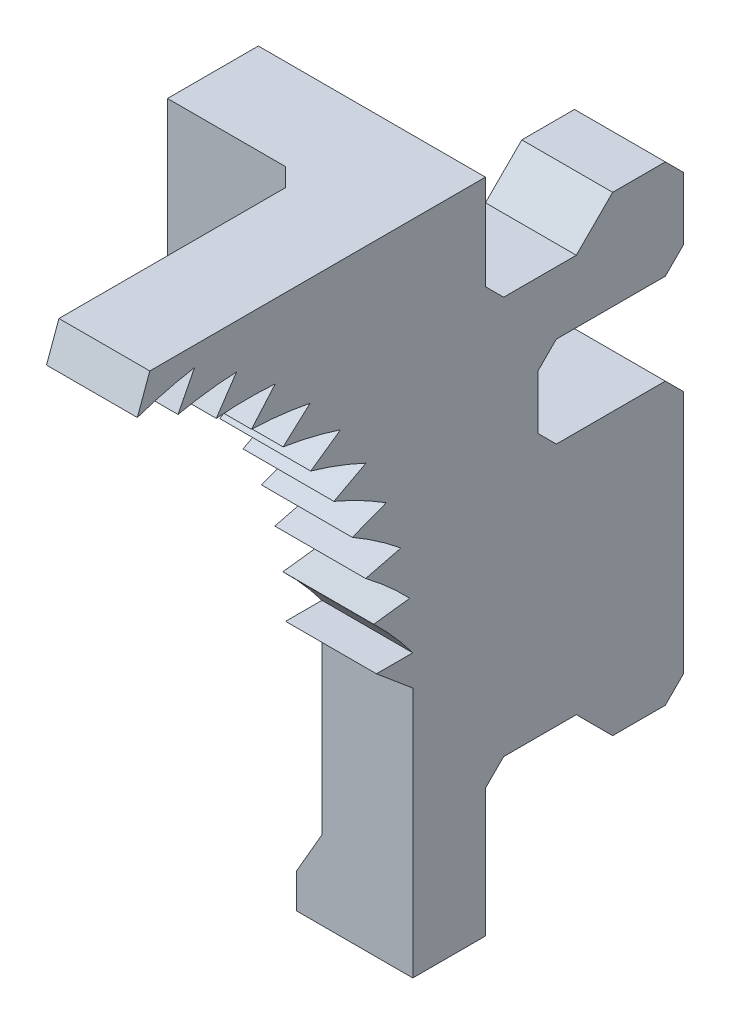
from build123d import *

# Parameters (mm, degrees)
EXTRUDE_1_DEPTH     = 2.5
EXTRUDE_START       = -2.5
EXTRUDE_2_DEPTH     = 5
EXTRUDE_4_DEPTH     = 4
SKETCH_9_W          = 5
SKETCH_9_H          = 5
CUT_EXTRUDE_4_DEPTH = 8
SKETCH_10_W         = 5
SKETCH_10_H         = 12.173237657
EXTRUDE_5_DEPTH     = 10
CHAMFER_2_SIZE      = 1
CHAMFER_3_SIZE      = 1


with BuildPart() as part:
    # 草图1 → 凸台-拉伸1 (new body, symmetric)
    with BuildSketch(Plane(origin=(0, 0, 0), x_dir=(0, 0, -1), z_dir=(1, 0, 0))):
        with BuildLine():
            ThreePointArc((-12.012209006, 35.102143532), (-13.602346238, 34.762025687), (-15.159597133, 34.293852416))
            Line((-15.159597133, 34.293852416), (-14.475556847, 36.173237657))
            Line((-14.475556847, 36.173237657), (0, 36.173237657))
            Line((0, 36.173237657), (4, 36.173237657))
            Line((4, 36.173237657), (4, 0))
            Line((4, 0), (0, 0))
            Line((0, 0), (0, 13.821800738))
            Line((0, 13.821800738), (-2, 15.5))
            Line((-2, 15.5), (0, 15.5))
            ThreePointArc((0, 15.5), (-1.024954416, 16.762412377), (-2.149076967, 17.937386868))
            Line((-2.149076967, 17.937386868), (-0.163984664, 18.181125555))
            ThreePointArc((-0.163984664, 18.181125555), (-1.335148592, 19.30921758), (-2.594085474, 20.338437912))
            Line((-2.594085474, 20.338437912), (-0.653494022, 20.822281703))
            ThreePointArc((-0.653494022, 20.822281703), (-1.953408107, 21.799236122), (-3.32839147, 22.667358991))
            Line((-3.32839147, 22.667358991), (-1.461230617, 23.38409489))
            ThreePointArc((-1.461230617, 23.38409489), (-2.870516133, 24.195347563), (-4.341048143, 24.889431256))
            Line((-4.341048143, 24.889431256), (-2.575152957, 25.828374381))
            ThreePointArc((-2.575152957, 25.828374381), (-4.072800703, 26.4618314), (-5.616959114, 26.971528727))
            Line((-5.616959114, 26.971528727), (-3.978655026, 28.1186816))
            ThreePointArc((-3.978655026, 28.1186816), (-5.542338523, 28.564899578), (-7.13710349, 28.882612127))
            Line((-7.13710349, 28.882612127), (-5.65081384, 30.22087334))
            ThreePointArc((-5.65081384, 30.22087334), (-7.257222169, 30.473200196), (-8.87881942, 30.594191604))
            Line((-8.87881942, 30.594191604), (-7.566701362, 32.103610765))
            ThreePointArc((-7.566701362, 32.103610765), (-9.191886676, 32.158284886), (-10.816141931, 32.080751451))
            Line((-10.816141931, 32.080751451), (-9.697756124, 33.738826596))
            ThreePointArc((-9.697756124, 33.738826596), (-11.317490652, 33.595032918), (-12.920190005, 33.320130484))
            Line((-12.920190005, 33.320130484), (-12.012209006, 35.102143532))
        make_face()
    extrude(amount=EXTRUDE_1_DEPTH, both=True)

    # 草图6 → 凸台-拉伸2 (add)
    with BuildSketch(Plane(origin=(0, 0, 0), x_dir=(0, 0, -1), z_dir=(1, 0, 0)).offset(EXTRUDE_START)):
        Polygon((14.9, 31.95), (11, 31.95), (9, 29.95), (5, 29.95), (4, 30.95), (4, 7.05), (5, 8.05), (9, 8.05), (11, 6.05), (14.9, 6.05), align=None)
    extrude(amount=EXTRUDE_2_DEPTH)

    # 草图8 → 凸台-拉伸4 (add)
    with BuildSketch(Plane.XY):
        Polygon((-2.5, 0), (-3.9, 0), (-3.9, 1.9), (-2.5, 4.324871131), align=None)
    extrude(amount=-EXTRUDE_4_DEPTH)

    # 草图9 → 切除-拉伸4 (cut)
    with BuildSketch(Plane(origin=(0, 0, -14.9), x_dir=(-1, 0, 0), z_dir=(0, 0, -1))):
        with Locations((0, 24)):
            Rectangle(SKETCH_9_W, SKETCH_9_H)
    extrude(amount=-CUT_EXTRUDE_4_DEPTH, mode=Mode.SUBTRACT)

    # 草图10 → 凸台-拉伸5 (add)
    with BuildSketch(Plane(origin=(0, 0, 0), x_dir=(0, 0, -1), z_dir=(1, 0, 0))):
        with Locations((1.5, 30.086618829)):
            Rectangle(SKETCH_10_W, SKETCH_10_H)
    extrude(amount=-EXTRUDE_5_DEPTH)

    # 倒角2
    chamfer_2_edges = [part.edges().sort_by_distance(p)[0] for p in [
        (0, 26.5, -14.9),
        (0, 21.5, -6.9),
        (0, 26.5, -6.9),
        (0, 21.5, -14.9),
        (0, 6.05, -14.9),
        (0, 31.95, -14.9),
    ]]
    chamfer(chamfer_2_edges, length=CHAMFER_2_SIZE)

    # 倒角3
    chamfer_3_edges = [part.edges().sort_by_distance(p)[0] for p in [
        (-2.5, 30.086618829, 1),
        (-2.5, 27.475, -4),
    ]]
    chamfer(chamfer_3_edges, length=CHAMFER_3_SIZE)


solid = part.part
